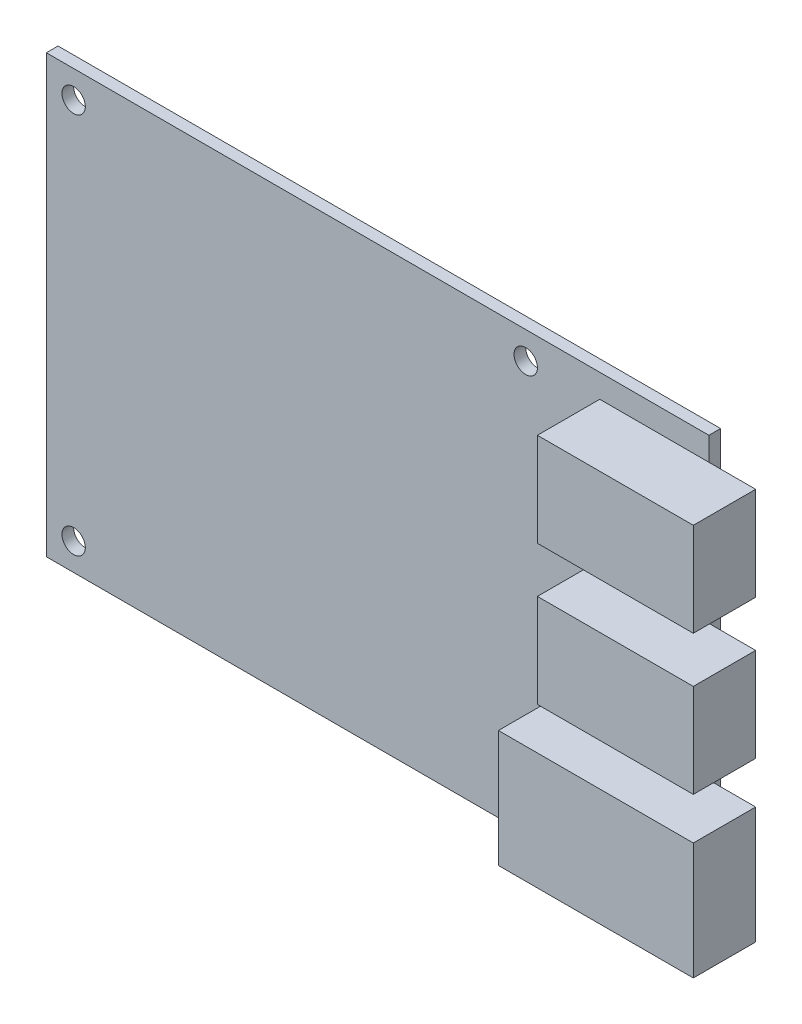
from build123d import *

# Parameters (mm, degrees)
SKETCH1_W           = 85
SKETCH1_H           = 56
SKETCH1_R           = 1.5
BOSS_EXTRUDE1_DEPTH = 1.5
SKETCH2_W           = 25
SKETCH2_H           = 15
SKETCH2_W_2         = 20
SKETCH2_H_2         = 12
BOSS_EXTRUDE2_DEPTH = 8


with BuildPart() as part:
    # Sketch1 → Boss-Extrude1 (new body)
    with BuildSketch(Plane.XY):
        Rectangle(SKETCH1_W, SKETCH1_H)
        with Locations((-39, 24.5)):
            Circle(SKETCH1_R, mode=Mode.SUBTRACT)
        with Locations((19, 24.5)):
            Circle(SKETCH1_R, mode=Mode.SUBTRACT)
        with Locations((19, -24.5)):
            Circle(SKETCH1_R, mode=Mode.SUBTRACT)
        with Locations((-39, -24.5)):
            Circle(SKETCH1_R, mode=Mode.SUBTRACT)
    extrude(amount=BOSS_EXTRUDE1_DEPTH)

    # Sketch2 → Boss-Extrude2 (add)
    with BuildSketch(Plane.XY.offset(1.5)):
        with Locations((36, -17.8)):
            Rectangle(SKETCH2_W, SKETCH2_H)
        with Locations((38.5, 1.1)):
            Rectangle(SKETCH2_W_2, SKETCH2_H_2)
        with Locations((38.5, 19)):
            Rectangle(SKETCH2_W_2, SKETCH2_H_2)
    extrude(amount=BOSS_EXTRUDE2_DEPTH)


solid = part.part
